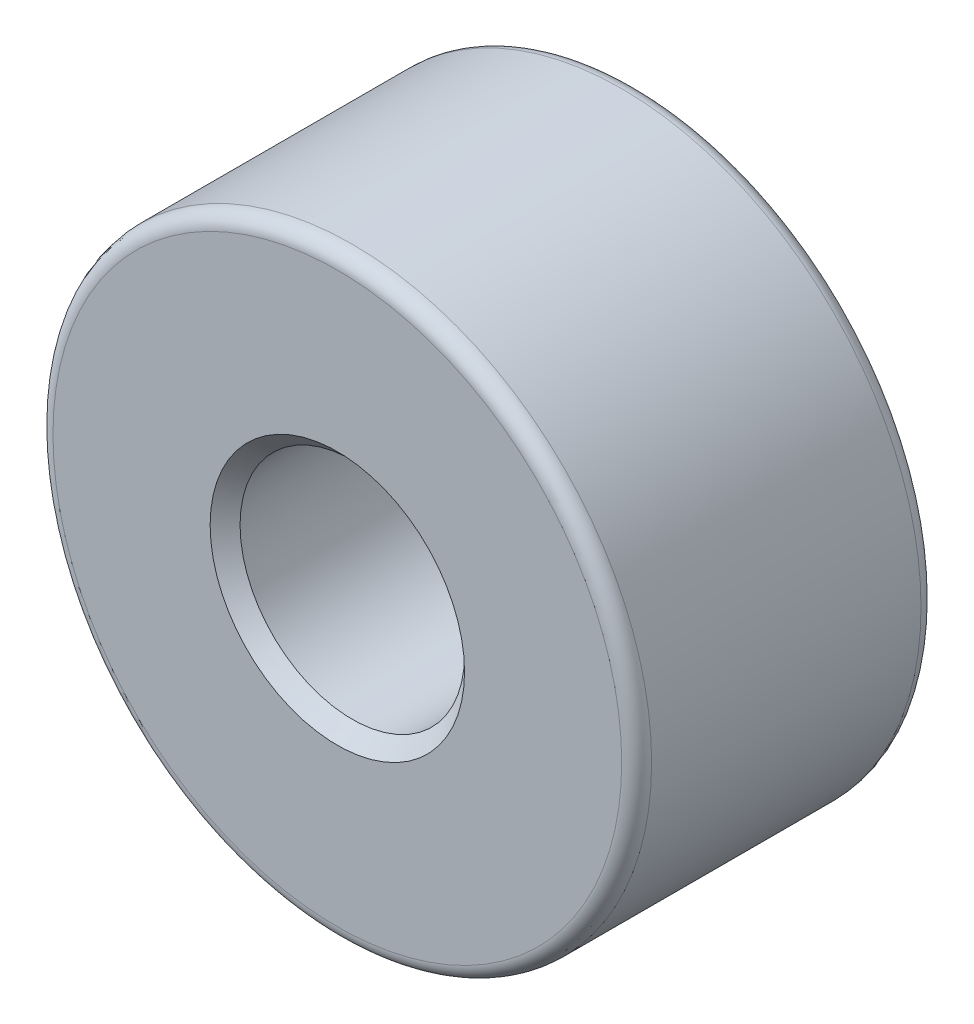
from build123d import *

# Parameters (mm, degrees)
SKIZZE1_R                       = 4
SKIZZE1_R_2                     = 1.5
AUFSATZ_LINEAR_AUSTRAGEN1_DEPTH = 4
FASE1_SIZE                      = 0.2
VERRUNDUNG1_R                   = 0.2


with BuildPart() as part:
    # Skizze1 → Aufsatz-Linear austragen1 (new body)
    with BuildSketch(Plane.XY):
        Circle(SKIZZE1_R)
        Circle(SKIZZE1_R_2, mode=Mode.SUBTRACT)
    extrude(amount=AUFSATZ_LINEAR_AUSTRAGEN1_DEPTH)

    # Fase1
    fase1_edges = [part.edges().sort_by_distance(p)[0] for p in [
        (-1.5, 0, 0),
        (-1.5, 0, 4),
    ]]
    chamfer(fase1_edges, length=FASE1_SIZE)

    # Verrundung1
    verrundung1_edges = [part.edges().sort_by_distance(p)[0] for p in [
        (-4, 0, 0),
        (-4, 0, 4),
    ]]
    fillet(verrundung1_edges, radius=VERRUNDUNG1_R)


solid = part.part
